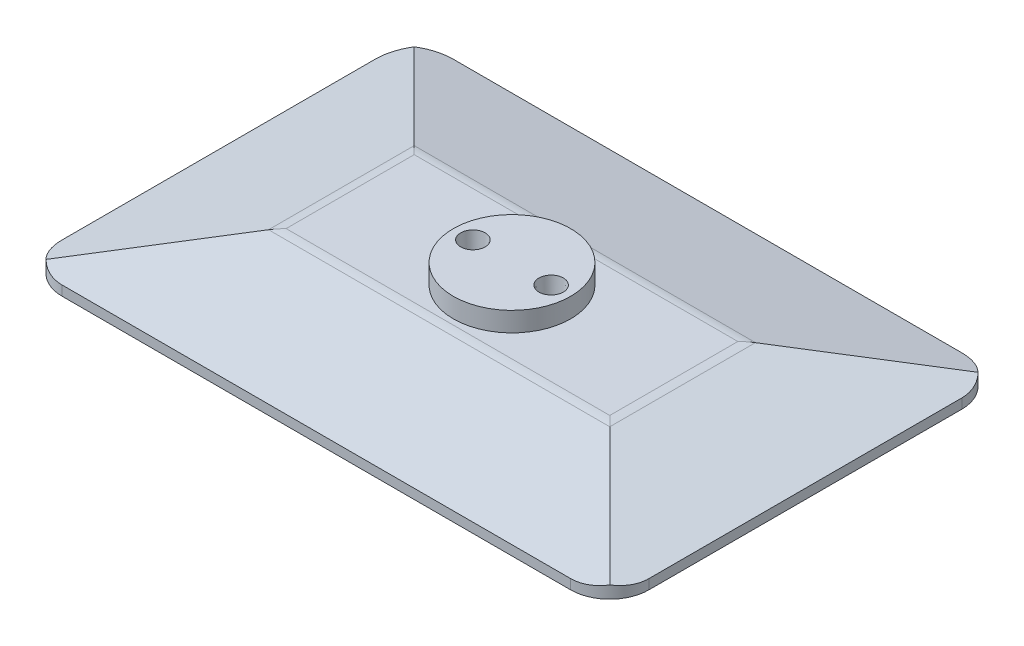
from build123d import *

# Parameters (mm, degrees)
SKETCH_1_W          = 60
SKETCH_1_H          = 40
EXTRUDE_1_DEPTH     = 1
SKETCH_2_W          = 60
SKETCH_2_H          = 40
EXTRUDE_2_DEPTH     = 3
EXTRUDE_2_TAPER     = 77
FILLET_1_R          = 4
SKETCH_3_R          = 6
EXTRUDE_3_DEPTH     = 2
FILLET_2_R          = 4
SKETCH_4_R          = 1.25
CUT_EXTRUDE_1_DEPTH = 3
CUT_EXTRUDE_1_TAPER = 5


with BuildPart() as part:
    # 草图1 → 凸台-拉伸1 (new body)
    with BuildSketch(Plane(origin=(0, 0, 0), x_dir=(1, 0, 0), z_dir=(0, 1, 0))):
        with Locations((5.975375352, -10.213749482)):
            Rectangle(SKETCH_1_W, SKETCH_1_H)
    extrude(amount=EXTRUDE_1_DEPTH)

    # 草图2 → 凸台-拉伸2 (add)
    with BuildSketch(Plane(origin=(0, 1, 0), x_dir=(1, 0, 0), z_dir=(0, 1, 0))):
        with Locations((5.975375352, -10.213749482)):
            Rectangle(SKETCH_2_W, SKETCH_2_H)
    extrude(amount=EXTRUDE_2_DEPTH, taper=EXTRUDE_2_TAPER)

    # 圆角1
    fillet_1_edges = [part.edges().sort_by_distance(p)[0] for p in [
        (35.975375352, 0.5, 30.213749482),
        (-24.024624648, 0.5, 30.213749482),
        (-24.024624648, 0.5, -9.786250518),
        (35.975375352, 0.5, -9.786250518),
    ]]
    fillet(fillet_1_edges, radius=FILLET_1_R)

    # 草图3 → 凸台-拉伸3 (add)
    with BuildSketch(Plane(origin=(0, 4, 0), x_dir=(1, 0, 0), z_dir=(0, 1, 0))):
        with Locations((5.975375352, -10.213749482)):
            Circle(SKETCH_3_R)
    extrude(amount=EXTRUDE_3_DEPTH)

    # 圆角2
    fillet_2_edges = [part.edges().sort_by_distance(p)[0] for p in [
        (5.975375352, 4, 17.219321859),
        (22.980947729, 4, 10.213749482),
        (5.975375352, 4, 3.208177105),
        (-11.030197026, 4, 10.213749482),
    ]]
    fillet(fillet_2_edges, radius=FILLET_2_R)

    # 草图4 → 切除-拉伸1 (cut)
    with BuildSketch(Plane(origin=(0, 6, 0), x_dir=(1, 0, 0), z_dir=(0, 1, 0))):
        with Locations((1.975375352, -10.213749482)):
            Circle(SKETCH_4_R)
        with Locations((9.975375352, -10.213749482)):
            Circle(SKETCH_4_R)
    extrude(amount=-CUT_EXTRUDE_1_DEPTH, taper=CUT_EXTRUDE_1_TAPER, mode=Mode.SUBTRACT)


solid = part.part
